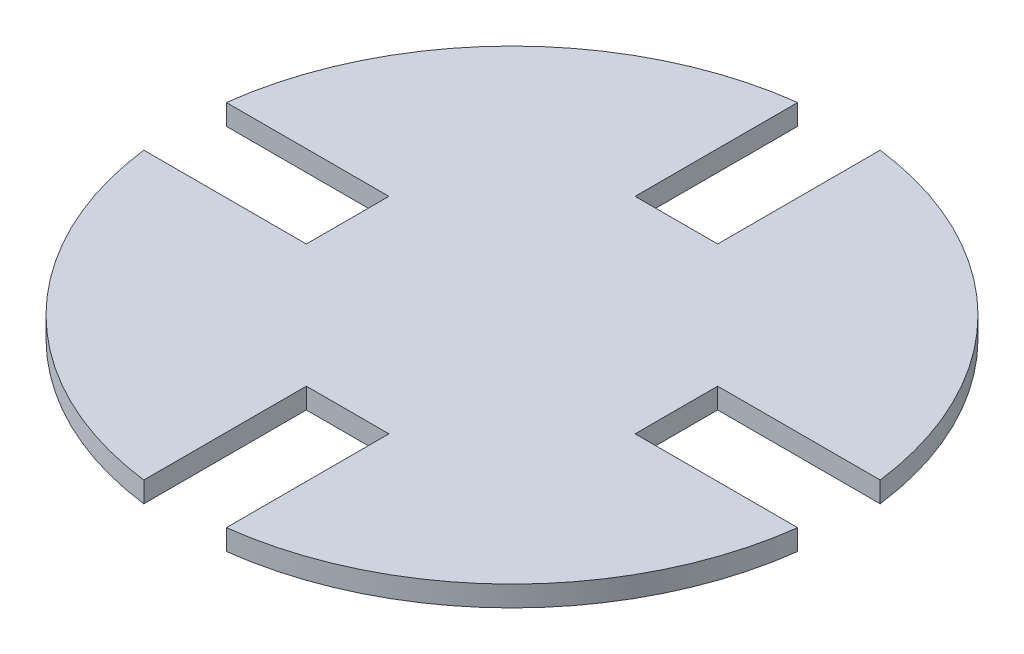
from build123d import *

# Parameters (mm, degrees)
SKETCH1_R           = 101.374642805
BOSS_EXTRUDE1_DEPTH = 6.35
CUT_EXTRUDE1_DEPTH  = 7.35


with BuildPart() as part:
    # Sketch1 → Boss-Extrude1 (new body)
    with BuildSketch(Plane(origin=(0, 0, 0), x_dir=(1, 0, 0), z_dir=(0, 1, 0))):
        Circle(SKETCH1_R)
    extrude(amount=BOSS_EXTRUDE1_DEPTH)

    # Sketch2 → Cut-Extrude1 (cut, through all)
    with BuildSketch(Plane(origin=(0, 6.35, 0), x_dir=(1, 0, 0), z_dir=(0, 1, 0))):
        with BuildLine():
            ThreePointArc((-101.374642805, 1.78e-07), (-101.174780653, -6.362543795), (-100.575982241, -12.7))
            Line((-100.575982241, -12.7), (-57.078868275, -12.7))
            Line((-57.078868275, -12.7), (-50.574642805, -12.7))
            Line((-50.574642805, -12.7), (-50.574642805, 12.7))
            Line((-50.574642805, 12.7), (-100.575982241, 12.7))
            ThreePointArc((-100.575982241, 12.7), (-101.174780642, 6.362543972), (-101.374642805, 1.78e-07))
        make_face()
        with BuildLine():
            ThreePointArc((2.49e-07, 101.374642805), (-6.36254376, 101.174780655), (-12.7, 100.575982241))
            Line((-12.7, 100.575982241), (-12.7, 57.078868275))
            Line((-12.7, 57.078868275), (-12.7, 50.574642805))
            Line((-12.7, 50.574642805), (12.7, 50.574642805))
            Line((12.7, 50.574642805), (12.7, 100.575982241))
            ThreePointArc((12.7, 100.575982241), (6.362544008, 101.17478064), (2.49e-07, 101.374642805))
        make_face()
        with BuildLine():
            Line((50.574642805, -12.7), (100.575982241, -12.7))
            ThreePointArc((100.575982241, -12.7), (101.174780648, -6.362543884), (101.374642805, 0))
            ThreePointArc((101.374642805, 0), (101.174780648, 6.362543884), (100.575982241, 12.7))
            Line((100.575982241, 12.7), (57.078868275, 12.7))
            Line((57.078868275, 12.7), (50.574642805, 12.7))
            Line((50.574642805, 12.7), (50.574642805, -12.7))
        make_face()
        with BuildLine():
            Line((12.7, -50.574642805), (-12.7, -50.574642805))
            Line((-12.7, -50.574642805), (-12.7, -100.575982241))
            ThreePointArc((-12.7, -100.575982241), (-6.362543952, -101.174780643), (-1.37e-07, -101.374642805))
            ThreePointArc((-1.37e-07, -101.374642805), (6.362543815, -101.174780652), (12.7, -100.575982241))
            Line((12.7, -100.575982241), (12.7, -57.078868275))
            Line((12.7, -57.078868275), (12.7, -50.574642805))
        make_face()
    extrude(amount=-CUT_EXTRUDE1_DEPTH, mode=Mode.SUBTRACT)


solid = part.part
